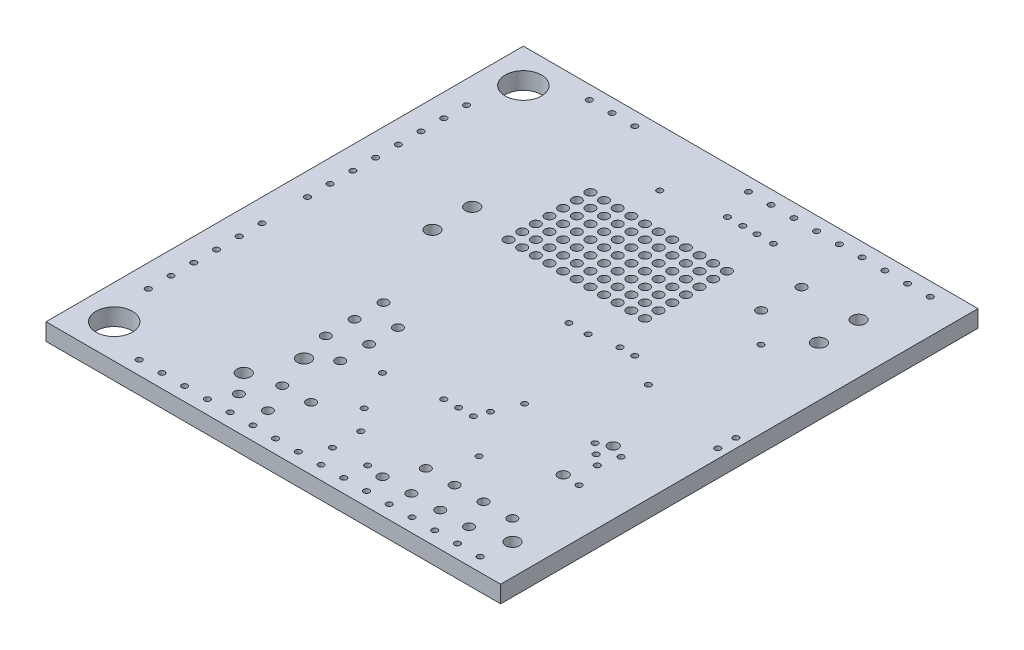
from build123d import *

# Parameters (mm, degrees)
SKETCH1_W           = 40
SKETCH1_H           = 42
BOSS_EXTRUDE1_DEPTH = 1.5
SKETCH3_R           = 0.254
SKETCH3_R_2         = 0.4064
SKETCH3_R_3         = 0.4445
SKETCH3_R_4         = 0.5969
SKETCH3_R_5         = 1.6002
CUT_EXTRUDE1_DEPTH  = 1.5


with BuildPart() as part:
    # Sketch1 → Boss-Extrude1 (new body)
    with BuildSketch(Plane(origin=(0, 0, 0), x_dir=(1, 0, 0), z_dir=(0, 1, 0))):
        with Locations((20, 21)):
            Rectangle(SKETCH1_W, SKETCH1_H)
    extrude(amount=BOSS_EXTRUDE1_DEPTH)

    # Sketch3 → Cut-Extrude1 (cut)
    with BuildSketch(Plane(origin=(0, 1.5, 0), x_dir=(1, 0, 0), z_dir=(0, 1, 0))):
        with Locations((37.000095711, 1.199200031)):
            Circle(SKETCH3_R)
        with Locations((34.998575711, 1.199200031)):
            Circle(SKETCH3_R)
        with Locations((32.999595711, 1.199200031)):
            Circle(SKETCH3_R)
        with Locations((31.000615711, 1.199200031)):
            Circle(SKETCH3_R)
        with Locations((28.999095711, 1.199200031)):
            Circle(SKETCH3_R)
        with Locations((27.000115711, 1.199200031)):
            Circle(SKETCH3_R)
        with Locations((24.998595711, 1.199200031)):
            Circle(SKETCH3_R)
        with Locations((22.999615711, 1.199200031)):
            Circle(SKETCH3_R)
        with Locations((22.199515711, 3.000060031)):
            Circle(SKETCH3_R)
        with Locations((21.000635711, 1.199200031)):
            Circle(SKETCH3_R)
        with Locations((18.999115711, 1.199200031)):
            Circle(SKETCH3_R)
        with Locations((17.000135711, 1.199200031)):
            Circle(SKETCH3_R)
        with Locations((14.998615711, 1.199200031)):
            Circle(SKETCH3_R)
        with Locations((12.999635711, 1.199200031)):
            Circle(SKETCH3_R)
        with Locations((11.000655711, 1.199200031)):
            Circle(SKETCH3_R)
        with Locations((8.999135711, 1.199200031)):
            Circle(SKETCH3_R)
        with Locations((7.000155711, 1.199200031)):
            Circle(SKETCH3_R)
        with Locations((1.998895711, 7.000560031)):
            Circle(SKETCH3_R)
        with Locations((1.998895711, 8.999540031)):
            Circle(SKETCH3_R)
        with Locations((1.998895711, 11.001060031)):
            Circle(SKETCH3_R)
        with Locations((1.998895711, 13.000040031)):
            Circle(SKETCH3_R)
        with Locations((1.998895711, 15.001560031)):
            Circle(SKETCH3_R)
        with Locations((1.998895711, 17.000540031)):
            Circle(SKETCH3_R)
        with Locations((1.998895711, 21.001040031)):
            Circle(SKETCH3_R)
        with Locations((1.998895711, 23.000020031)):
            Circle(SKETCH3_R)
        with Locations((1.998895711, 25.001540031)):
            Circle(SKETCH3_R)
        with Locations((1.998895711, 27.000520031)):
            Circle(SKETCH3_R)
        with Locations((1.998895711, 28.999500031)):
            Circle(SKETCH3_R)
        with Locations((1.998895711, 31.001020031)):
            Circle(SKETCH3_R)
        with Locations((1.998895711, 33.000000031)):
            Circle(SKETCH3_R)
        with Locations((1.998895711, 35.001520031)):
            Circle(SKETCH3_R)
        with Locations((7.000155711, 40.800340031)):
            Circle(SKETCH3_R)
        with Locations((8.999135711, 40.800340031)):
            Circle(SKETCH3_R)
        with Locations((11.000655711, 40.800340031)):
            Circle(SKETCH3_R)
        with Locations((17.000135711, 37.000500031)):
            Circle(SKETCH3_R)
        with Locations((21.000635711, 40.800340031)):
            Circle(SKETCH3_R)
        with Locations((22.999615711, 40.800340031)):
            Circle(SKETCH3_R)
        with Locations((24.998595711, 40.800340031)):
            Circle(SKETCH3_R)
        with Locations((27.000115711, 40.800340031)):
            Circle(SKETCH3_R)
        with Locations((28.999095711, 40.800340031)):
            Circle(SKETCH3_R)
        with Locations((31.000615711, 40.800340031)):
            Circle(SKETCH3_R)
        with Locations((32.999595711, 40.800340031)):
            Circle(SKETCH3_R)
        with Locations((34.998575711, 40.800340031)):
            Circle(SKETCH3_R)
        with Locations((37.000095711, 40.800340031)):
            Circle(SKETCH3_R)
        with Locations((26.050155711, 37.950460031)):
            Circle(SKETCH3_R)
        with Locations((24.599815711, 37.950460031)):
            Circle(SKETCH3_R)
        with Locations((23.350135711, 37.950460031)):
            Circle(SKETCH3_R)
        with Locations((21.998855711, 37.950460031)):
            Circle(SKETCH3_R)
        with Locations((33.200255711, 29.700540031)):
            Circle(SKETCH3_R)
        with Locations((28.498715711, 23.299740031)):
            Circle(SKETCH3_R)
        with Locations((27.200775711, 23.299740031)):
            Circle(SKETCH3_R)
        with Locations((24.800475711, 22.900960031)):
            Circle(SKETCH3_R)
        with Locations((23.098675711, 22.900960031)):
            Circle(SKETCH3_R)
        with Locations((31.300335711, 21.699540031)):
            Circle(SKETCH3_R)
        with Locations((33.398375711, 14.899960031)):
            Circle(SKETCH3_R)
        with Locations((34.300075711, 14.099860031)):
            Circle(SKETCH3_R)
        with Locations((35.199235711, 13.299760031)):
            Circle(SKETCH3_R)
        with Locations((35.600555711, 15.001560031)):
            Circle(SKETCH3_R)
        with Locations((35.900275711, 11.001060031)):
            Circle(SKETCH3_R)
        with Locations((29.298815711, 8.801420031)):
            Circle(SKETCH3_R)
        with Locations((25.999355711, 11.600500031)):
            Circle(SKETCH3_R)
        with Locations((26.400675711, 12.700320031)):
            Circle(SKETCH3_R)
        with Locations((24.698875711, 11.600500031)):
            Circle(SKETCH3_R)
        with Locations((23.398395711, 11.600500031)):
            Circle(SKETCH3_R)
        with Locations((27.299835711, 14.800900031)):
            Circle(SKETCH3_R)
        with Locations((20.599315711, 7.399340031)):
            Circle(SKETCH3_R)
        with Locations((22.199515711, 5.499420031)):
            Circle(SKETCH3_R)
        with Locations((25.100195711, 3.200720031)):
            Circle(SKETCH3_R)
        with Locations((18.699395711, 10.899460031)):
            Circle(SKETCH3_R)
        with Locations((39.199735711, 19.901220031)):
            Circle(SKETCH3_R)
        with Locations((39.199735711, 21.501420031)):
            Circle(SKETCH3_R)
        with Locations((26.098415711, 26.599200031)):
            Circle(SKETCH3_R_2)
        with Locations((26.098415711, 27.800620031)):
            Circle(SKETCH3_R_2)
        with Locations((24.899535711, 27.800620031)):
            Circle(SKETCH3_R_2)
        with Locations((24.899535711, 26.599200031)):
            Circle(SKETCH3_R_2)
        with Locations((23.700655711, 26.599200031)):
            Circle(SKETCH3_R_2)
        with Locations((23.700655711, 27.800620031)):
            Circle(SKETCH3_R_2)
        with Locations((23.700655711, 28.999500031)):
            Circle(SKETCH3_R_2)
        with Locations((24.899535711, 28.999500031)):
            Circle(SKETCH3_R_2)
        with Locations((26.098415711, 28.999500031)):
            Circle(SKETCH3_R_2)
        with Locations((26.098415711, 30.200920031)):
            Circle(SKETCH3_R_2)
        with Locations((24.899535711, 30.200920031)):
            Circle(SKETCH3_R_2)
        with Locations((24.899535711, 31.399800031)):
            Circle(SKETCH3_R_2)
        with Locations((23.700655711, 31.399800031)):
            Circle(SKETCH3_R_2)
        with Locations((23.700655711, 30.200920031)):
            Circle(SKETCH3_R_2)
        with Locations((22.499235711, 30.200920031)):
            Circle(SKETCH3_R_2)
        with Locations((21.300355711, 30.200920031)):
            Circle(SKETCH3_R_2)
        with Locations((21.300355711, 31.399800031)):
            Circle(SKETCH3_R_2)
        with Locations((22.499235711, 31.399800031)):
            Circle(SKETCH3_R_2)
        with Locations((22.499235711, 32.601220031)):
            Circle(SKETCH3_R_2)
        with Locations((22.499235711, 33.800100031)):
            Circle(SKETCH3_R_2)
        with Locations((21.300355711, 33.800100031)):
            Circle(SKETCH3_R_2)
        with Locations((21.300355711, 32.601220031)):
            Circle(SKETCH3_R_2)
        with Locations((20.098935711, 32.601220031)):
            Circle(SKETCH3_R_2)
        with Locations((20.098935711, 33.800100031)):
            Circle(SKETCH3_R_2)
        with Locations((18.900055711, 33.800100031)):
            Circle(SKETCH3_R_2)
        with Locations((18.900055711, 32.601220031)):
            Circle(SKETCH3_R_2)
        with Locations((17.698635711, 32.601220031)):
            Circle(SKETCH3_R_2)
        with Locations((17.698635711, 33.800100031)):
            Circle(SKETCH3_R_2)
        with Locations((16.499755711, 33.800100031)):
            Circle(SKETCH3_R_2)
        with Locations((16.499755711, 32.601220031)):
            Circle(SKETCH3_R_2)
        with Locations((15.298335711, 32.601220031)):
            Circle(SKETCH3_R_2)
        with Locations((14.099455711, 32.601220031)):
            Circle(SKETCH3_R_2)
        with Locations((14.099455711, 33.800100031)):
            Circle(SKETCH3_R_2)
        with Locations((15.298335711, 33.800100031)):
            Circle(SKETCH3_R_2)
        with Locations((15.298335711, 31.399800031)):
            Circle(SKETCH3_R_2)
        with Locations((14.099455711, 31.399800031)):
            Circle(SKETCH3_R_2)
        with Locations((14.099455711, 30.200920031)):
            Circle(SKETCH3_R_2)
        with Locations((15.298335711, 30.200920031)):
            Circle(SKETCH3_R_2)
        with Locations((15.298335711, 28.999500031)):
            Circle(SKETCH3_R_2)
        with Locations((14.099455711, 28.999500031)):
            Circle(SKETCH3_R_2)
        with Locations((14.099455711, 27.800620031)):
            Circle(SKETCH3_R_2)
        with Locations((15.298335711, 27.800620031)):
            Circle(SKETCH3_R_2)
        with Locations((15.298335711, 26.599200031)):
            Circle(SKETCH3_R_2)
        with Locations((14.099455711, 26.599200031)):
            Circle(SKETCH3_R_2)
        with Locations((16.499755711, 26.599200031)):
            Circle(SKETCH3_R_2)
        with Locations((16.499755711, 27.800620031)):
            Circle(SKETCH3_R_2)
        with Locations((17.698635711, 27.800620031)):
            Circle(SKETCH3_R_2)
        with Locations((17.698635711, 26.599200031)):
            Circle(SKETCH3_R_2)
        with Locations((18.900055711, 26.599200031)):
            Circle(SKETCH3_R_2)
        with Locations((18.900055711, 27.800620031)):
            Circle(SKETCH3_R_2)
        with Locations((20.098935711, 27.800620031)):
            Circle(SKETCH3_R_2)
        with Locations((20.098935711, 26.599200031)):
            Circle(SKETCH3_R_2)
        with Locations((21.300355711, 26.599200031)):
            Circle(SKETCH3_R_2)
        with Locations((22.499235711, 26.599200031)):
            Circle(SKETCH3_R_2)
        with Locations((22.499235711, 27.800620031)):
            Circle(SKETCH3_R_2)
        with Locations((21.300355711, 27.800620031)):
            Circle(SKETCH3_R_2)
        with Locations((21.300355711, 28.999500031)):
            Circle(SKETCH3_R_2)
        with Locations((22.499235711, 28.999500031)):
            Circle(SKETCH3_R_2)
        with Locations((20.098935711, 28.999500031)):
            Circle(SKETCH3_R_2)
        with Locations((18.900055711, 28.999500031)):
            Circle(SKETCH3_R_2)
        with Locations((17.698635711, 28.999500031)):
            Circle(SKETCH3_R_2)
        with Locations((16.499755711, 28.999500031)):
            Circle(SKETCH3_R_2)
        with Locations((16.499755711, 30.200920031)):
            Circle(SKETCH3_R_2)
        with Locations((16.499755711, 31.399800031)):
            Circle(SKETCH3_R_2)
        with Locations((17.698635711, 31.399800031)):
            Circle(SKETCH3_R_2)
        with Locations((17.698635711, 30.200920031)):
            Circle(SKETCH3_R_2)
        with Locations((18.900055711, 30.200920031)):
            Circle(SKETCH3_R_2)
        with Locations((20.098935711, 30.200920031)):
            Circle(SKETCH3_R_2)
        with Locations((20.098935711, 31.399800031)):
            Circle(SKETCH3_R_2)
        with Locations((18.900055711, 31.399800031)):
            Circle(SKETCH3_R_2)
        with Locations((23.700655711, 32.601220031)):
            Circle(SKETCH3_R_2)
        with Locations((23.700655711, 33.800100031)):
            Circle(SKETCH3_R_2)
        with Locations((24.899535711, 33.800100031)):
            Circle(SKETCH3_R_2)
        with Locations((24.899535711, 32.601220031)):
            Circle(SKETCH3_R_2)
        with Locations((26.098415711, 32.601220031)):
            Circle(SKETCH3_R_2)
        with Locations((26.098415711, 33.800100031)):
            Circle(SKETCH3_R_2)
        with Locations((26.098415711, 31.399800031)):
            Circle(SKETCH3_R_2)
        with Locations((30.599295711, 32.321820031)):
            Circle(SKETCH3_R_2)
        with Locations((30.599295711, 35.877820031)):
            Circle(SKETCH3_R_2)
        with Locations((13.390795711, 16.304580031)):
            Circle(SKETCH3_R_2)
        with Locations((13.390795711, 13.764580031)):
            Circle(SKETCH3_R_2)
        with Locations((13.390795711, 11.224580031)):
            Circle(SKETCH3_R_2)
        with Locations((15.930795711, 9.954580031)):
            Circle(SKETCH3_R_2)
        with Locations((15.930795711, 12.494580031)):
            Circle(SKETCH3_R_2)
        with Locations((15.930795711, 15.034580031)):
            Circle(SKETCH3_R_2)
        with Locations((15.265315711, 5.519740031)):
            Circle(SKETCH3_R_2)
        with Locations((17.805315711, 5.519740031)):
            Circle(SKETCH3_R_2)
        with Locations((16.535315711, 2.979740031)):
            Circle(SKETCH3_R_2)
        with Locations((13.995315711, 2.979740031)):
            Circle(SKETCH3_R_2)
        with Locations((26.614035711, 2.989900031)):
            Circle(SKETCH3_R_2)
        with Locations((29.154035711, 2.989900031)):
            Circle(SKETCH3_R_2)
        with Locations((31.694035711, 2.989900031)):
            Circle(SKETCH3_R_2)
        with Locations((34.234035711, 2.989900031)):
            Circle(SKETCH3_R_2)
        with Locations((32.964035711, 5.529900031)):
            Circle(SKETCH3_R_2)
        with Locations((30.424035711, 5.529900031)):
            Circle(SKETCH3_R_2)
        with Locations((27.884035711, 5.529900031)):
            Circle(SKETCH3_R_2)
        with Locations((35.504035711, 5.529900031)):
            Circle(SKETCH3_R_2)
        with Locations((34.419455711, 11.089960031)):
            Circle(SKETCH3_R_3)
        with Locations((34.419455711, 15.489240031)):
            Circle(SKETCH3_R_3)
        with Locations((37.299815711, 3.749360031)):
            Circle(SKETCH3_R_4)
        with Locations((14.150255711, 8.549960031)):
            Circle(SKETCH3_R_4)
        with Locations((12.598315711, 4.800920031)):
            Circle(SKETCH3_R_4)
        with Locations((9.999895711, 24.000780031)):
            Circle(SKETCH3_R_4)
        with Locations((9.999895711, 27.500900031)):
            Circle(SKETCH3_R_4)
        with Locations((35.600555711, 32.400560031)):
            Circle(SKETCH3_R_4)
        with Locations((35.600555711, 35.900680031)):
            Circle(SKETCH3_R_4)
        with Locations((2.999655711, 38.999480031)):
            Circle(SKETCH3_R_5)
        with Locations((2.999655711, 3.000060031)):
            Circle(SKETCH3_R_5)
    extrude(amount=-CUT_EXTRUDE1_DEPTH, mode=Mode.SUBTRACT)


solid = part.part
